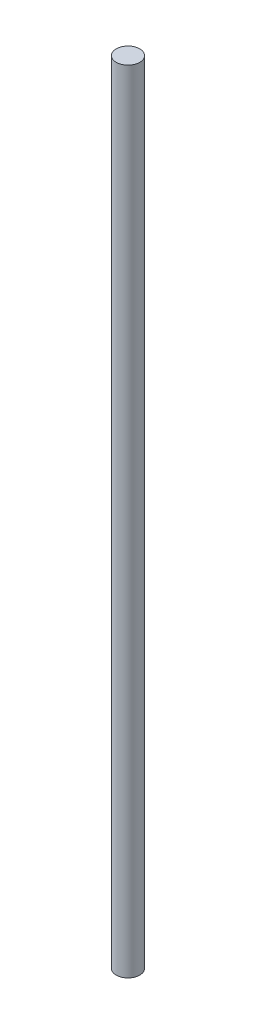
from build123d import *

# Parameters (mm, degrees)
SKETCH_1_R      = 4
EXTRUDE_1_DEPTH = 270


with BuildPart() as part:
    # 草图1 → 凸台-拉伸1 (new body)
    with BuildSketch(Plane(origin=(0, 0, 0), x_dir=(1, 0, 0), z_dir=(0, 1, 0))):
        Circle(SKETCH_1_R)
    extrude(amount=EXTRUDE_1_DEPTH)


solid = part.part
